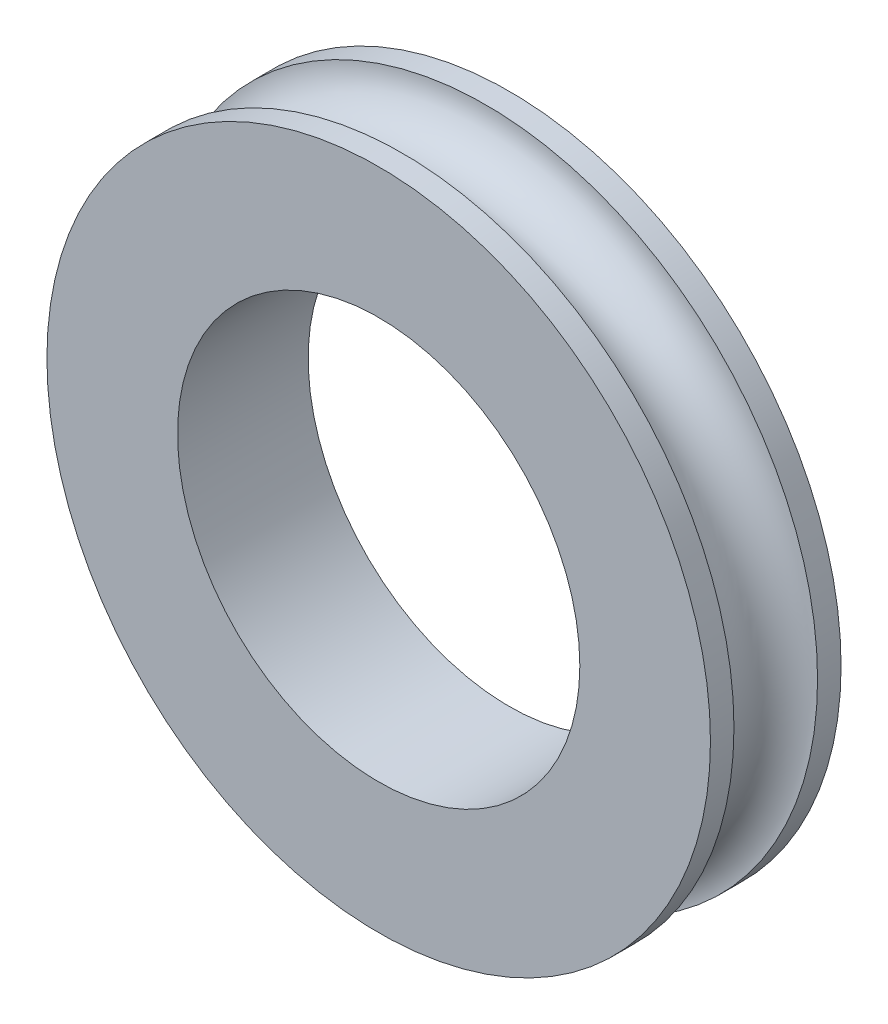
from build123d import *


with BuildPart() as part:
    # Sketch1 → Revolve1 (revolve)
    with BuildSketch(Plane(origin=(0, 0, 0), x_dir=(0, 0, -1), z_dir=(1, 0, 0))):
        with BuildLine():
            Line((0, 3.85), (2.5, 3.85))
            Line((2.5, 3.85), (2.5, 6.35))
            Line((2.5, 6.35), (2.05, 6.35))
            ThreePointArc((2.05, 6.35), (1.25, 5.55), (0.45, 6.35))
            Line((0.45, 6.35), (0, 6.35))
            Line((0, 6.35), (0, 3.85))
        make_face()
    revolve(axis=Axis((0, 0, 0), (0, 0, -1)))


solid = part.part
